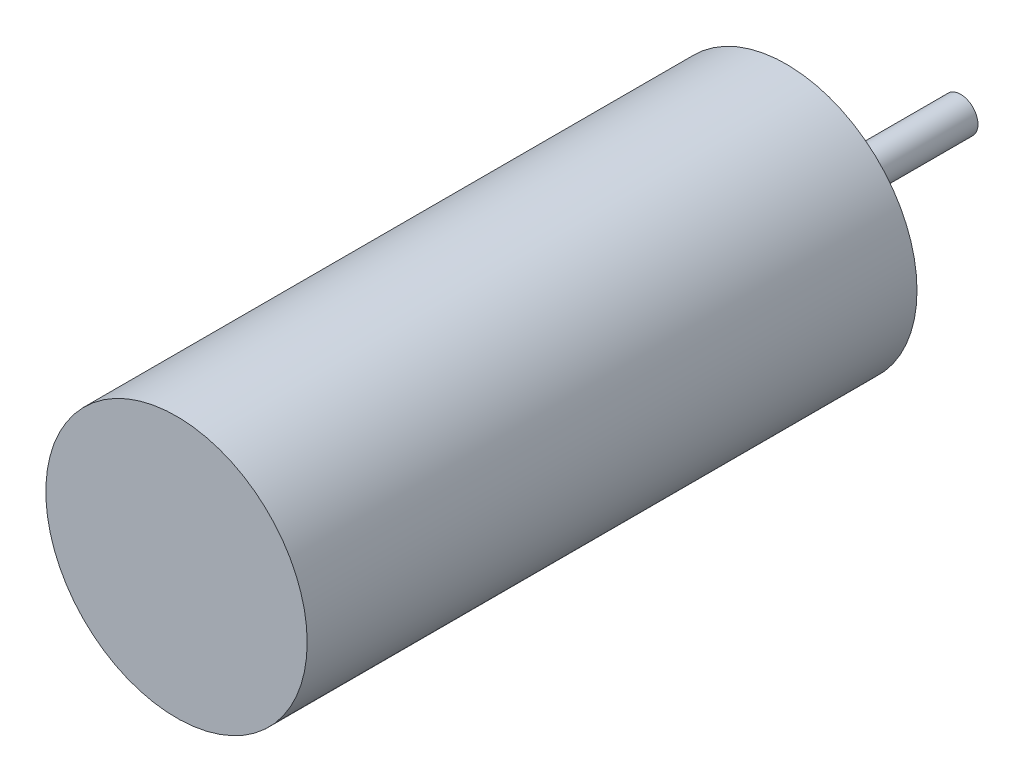
from build123d import *

# Parameters (mm, degrees)
SKETCH_1_R      = 3
EXTRUDE_1_DEPTH = 14
SKETCH_2_R      = 0.4
EXTRUDE_2_DEPTH = 4


with BuildPart() as part:
    # 스케치1 → 보스-돌출1 (new body)
    with BuildSketch(Plane.XY):
        Circle(SKETCH_1_R)
    extrude(amount=EXTRUDE_1_DEPTH)

    # 스케치2 → 보스-돌출2 (add)
    with BuildSketch(Plane(origin=(0, 0, 0), x_dir=(-1, 0, 0), z_dir=(0, 0, -1))):
        Circle(SKETCH_2_R)
    extrude(amount=EXTRUDE_2_DEPTH)


solid = part.part
